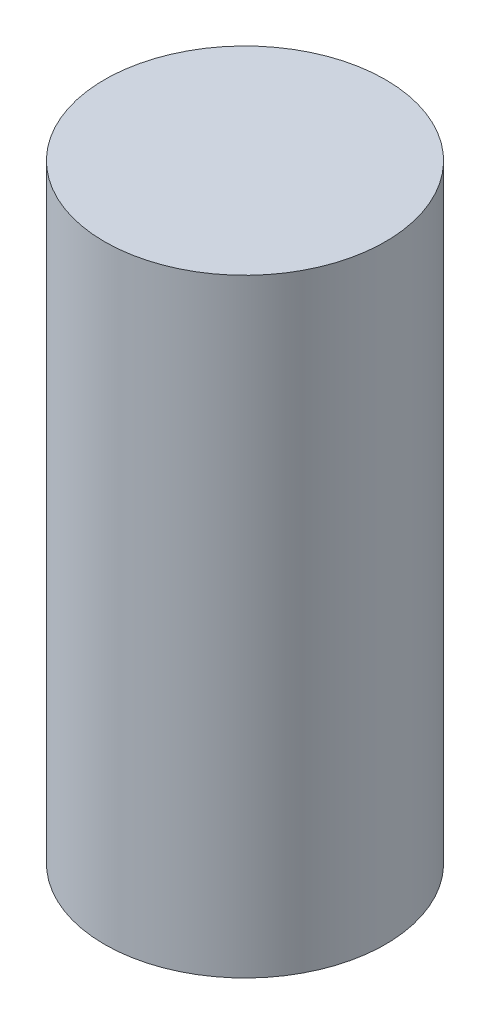
from build123d import *

# Parameters (mm, degrees)
SKETCH1_R           = 3
BOSS_EXTRUDE1_DEPTH = 13


with BuildPart() as part:
    # Sketch1 → Boss-Extrude1 (new body)
    with BuildSketch(Plane(origin=(0, 0, 0), x_dir=(1, 0, 0), z_dir=(0, 1, 0))):
        Circle(SKETCH1_R)
    extrude(amount=BOSS_EXTRUDE1_DEPTH)


solid = part.part
